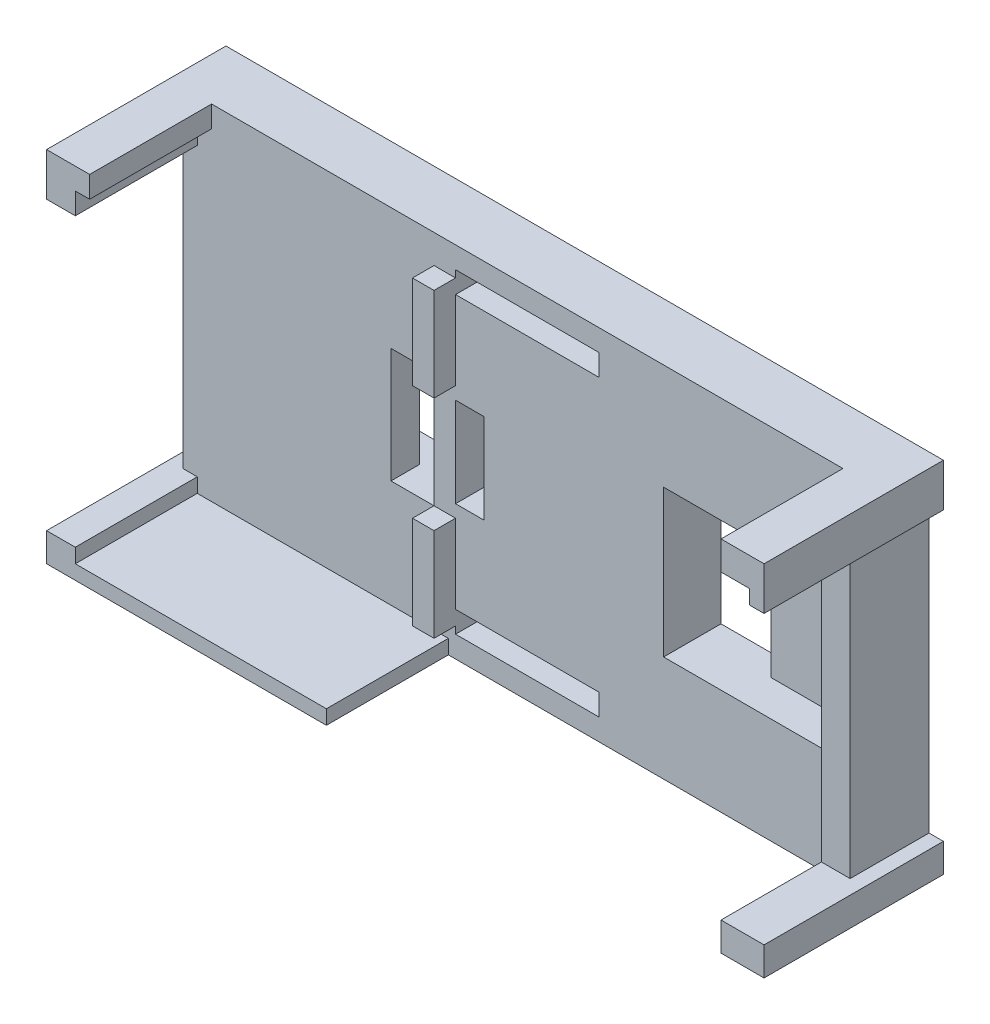
from build123d import *

# Parameters (mm, degrees)
SKIZZE1_W                            = 100
SKIZZE1_H                            = 50
SKIZZE1_W_2                          = 20
SKIZZE1_H_2                          = 3
AUFSATZ_LINEAR_AUSTRAGEN1_DEPTH      = 3
SKIZZE2_W                            = 90
SKIZZE2_H                            = 25
AUFSATZ_LINEAR_AUSTRAGEN2_DEPTH      = 5
SCHNITT_LINEAR_AUSTRAGEN1_DEPTH      = 4
SKIZZE4_W                            = 6
SKIZZE4_H                            = 16
SCHNITT_LINEAR_AUSTRAGEN2_DEPTH      = 5
SCHNITT_LINEAR_AUSTRAGEN2_DEPTH_BACK = 5
SKIZZE5_W                            = 25
SKIZZE5_H                            = 12.5
SCHNITT_LINEAR_AUSTRAGEN3_DEPTH      = 5.6
SKIZZE6_W                            = 4
SKIZZE6_H                            = 12.5
SCHNITT_LINEAR_AUSTRAGEN4_DEPTH      = 6.6
SCHNITT_LINEAR_AUSTRAGEN4_DEPTH_BACK = 3.4
SKIZZE8_W                            = 13
SKIZZE8_H                            = 20.5
SCHNITT_LINEAR_AUSTRAGEN5_DEPTH      = 5
SKIZZE9_W                            = 10
SKIZZE9_H                            = 20.5
SCHNITT_LINEAR_AUSTRAGEN6_DEPTH      = 8
AUFSATZ_LINEAR_AUSTRAGEN3_DEPTH      = 1
AUFSATZ_LINEAR_AUSTRAGEN4_DEPTH      = 17
SKIZZE14_W                           = 3
SKIZZE14_H                           = 42
AUFSATZ_LINEAR_AUSTRAGEN5_DEPTH      = 3
SKIZZE15_W                           = 3
SKIZZE15_H                           = 16
SCHNITT_LINEAR_AUSTRAGEN7_DEPTH      = 3
SKIZZE16_W                           = 2
SKIZZE16_H                           = 2
AUFSATZ_LINEAR_AUSTRAGEN6_DEPTH      = 17
SKIZZE17_W                           = 2
SKIZZE17_H                           = 40
SCHNITT_LINEAR_AUSTRAGEN8_DEPTH      = 20
SKIZZE18_W                           = 35
SKIZZE18_H                           = 2
SCHNITT_LINEAR_AUSTRAGEN9_DEPTH      = 17
SKIZZE19_W                           = 2
SKIZZE19_H                           = 6
SKIZZE19_W_2                         = 4
SKIZZE19_H_2                         = 4
AUFSATZ_LINEAR_AUSTRAGEN7_DEPTH      = 17
SKIZZE20_W                           = 1
SKIZZE20_H                           = 42
AUFSATZ_LINEAR_AUSTRAGEN8_DEPTH      = 3
SKIZZE21_W                           = 2
SKIZZE21_H                           = 3
AUFSATZ_LINEAR_AUSTRAGEN9_DEPTH      = 17
SKIZZE22_W                           = 20
SKIZZE22_H                           = 3
SKIZZE22_W_2                         = 90
SKIZZE22_H_2                         = 25
AUFSATZ_LINEAR_AUSTRAGEN10_DEPTH     = 5
SKIZZE24_W                           = 2
SKIZZE24_H                           = 4
AUFSATZ_LINEAR_AUSTRAGEN11_DEPTH     = 17


with BuildPart() as part:
    # Skizze1 → Aufsatz-Linear austragen1 (new body)
    with BuildSketch(Plane.XY):
        Rectangle(SKIZZE1_W, SKIZZE1_H)
        with Locations((0, -20.5)):
            Rectangle(SKIZZE1_W_2, SKIZZE1_H_2, mode=Mode.SUBTRACT)
        with Locations((0, 20.5)):
            Rectangle(SKIZZE1_W_2, SKIZZE1_H_2, mode=Mode.SUBTRACT)
    extrude(amount=AUFSATZ_LINEAR_AUSTRAGEN1_DEPTH)

    # Skizze2 → Aufsatz-Linear austragen2 (add)
    with BuildSketch(Plane(origin=(0, 0, 0), x_dir=(-1, 0, 0), z_dir=(0, 0, -1))):
        Rectangle(SKIZZE2_W, SKIZZE2_H)
    extrude(amount=AUFSATZ_LINEAR_AUSTRAGEN2_DEPTH)

    # Skizze3 → Schnitt-Linear austragen1 (cut)
    with BuildSketch(Plane(origin=(0, 0, -5), x_dir=(-1, 0, 0), z_dir=(0, 0, -1))):
        with BuildLine():
            Line((33, -8), (13, -8))
            Line((13, -8), (13, 8))
            Line((13, 8), (33, 8))
            ThreePointArc((33, 8), (41, 0), (33, -8))
        make_face()
    extrude(amount=-SCHNITT_LINEAR_AUSTRAGEN1_DEPTH, mode=Mode.SUBTRACT)

    # Skizze4 → Schnitt-Linear austragen2 (cut, two sides)
    with BuildSketch(Plane(origin=(0, 0, -1), x_dir=(-1, 0, 0), z_dir=(0, 0, -1))) as schnitt_linear_austragen2_sk:
        with Locations((16, 0)):
            Rectangle(SKIZZE4_W, SKIZZE4_H)
    extrude(amount=SCHNITT_LINEAR_AUSTRAGEN2_DEPTH, mode=Mode.SUBTRACT)
    extrude(schnitt_linear_austragen2_sk.sketch, amount=-SCHNITT_LINEAR_AUSTRAGEN2_DEPTH_BACK, mode=Mode.SUBTRACT)

    # Skizze5 → Schnitt-Linear austragen3 (cut)
    with BuildSketch(Plane(origin=(0, 0, -5), x_dir=(-1, 0, 0), z_dir=(0, 0, -1))):
        with Locations((-2.5, 0)):
            Rectangle(SKIZZE5_W, SKIZZE5_H)
    extrude(amount=-SCHNITT_LINEAR_AUSTRAGEN3_DEPTH, mode=Mode.SUBTRACT)

    # Skizze6 → Schnitt-Linear austragen4 (cut, two sides)
    with BuildSketch(Plane(origin=(0, 0, 0.6), x_dir=(-1, 0, 0), z_dir=(0, 0, -1))) as schnitt_linear_austragen4_sk:
        with Locations((8, 0)):
            Rectangle(SKIZZE6_W, SKIZZE6_H)
    extrude(amount=SCHNITT_LINEAR_AUSTRAGEN4_DEPTH, mode=Mode.SUBTRACT)
    extrude(schnitt_linear_austragen4_sk.sketch, amount=-SCHNITT_LINEAR_AUSTRAGEN4_DEPTH_BACK, mode=Mode.SUBTRACT)

    # Skizze8 → Schnitt-Linear austragen5 (cut)
    with BuildSketch(Plane.XY.offset(3)):
        with Locations((35.5, 0)):
            Rectangle(SKIZZE8_W, SKIZZE8_H)
    extrude(amount=-SCHNITT_LINEAR_AUSTRAGEN5_DEPTH, mode=Mode.SUBTRACT)

    # Skizze9 → Schnitt-Linear austragen6 (cut)
    with BuildSketch(Plane.XY.offset(3)):
        with Locations((24, 0)):
            Rectangle(SKIZZE9_W, SKIZZE9_H)
    extrude(amount=-SCHNITT_LINEAR_AUSTRAGEN6_DEPTH, mode=Mode.SUBTRACT)

    # Skizze10 → Aufsatz-Linear austragen3 (add)
    with BuildSketch(Plane(origin=(0, 0, -5), x_dir=(-1, 0, 0), z_dir=(0, 0, -1))):
        with BuildLine():
            Line((38.291502622, -6), (38.291502622, 6))
            ThreePointArc((38.291502622, 6), (41, 0), (38.291502622, -6))
        make_face()
    extrude(amount=-AUFSATZ_LINEAR_AUSTRAGEN3_DEPTH)

    # Skizze11 → Aufsatz-Linear austragen4 (add)
    with BuildSketch(Plane.XY.offset(3)):
        Polygon((-50, 25), (-50, -25), (-48, -25), (-11, -25), (-11, -23), (-48, -23), (-48, 25), align=None)
        Polygon((50, -25), (50, 25), (48, 25), (48, -23), (11, -23), (11, -25), align=None)
    extrude(amount=AUFSATZ_LINEAR_AUSTRAGEN4_DEPTH)

    # Skizze14 → Aufsatz-Linear austragen5 (add)
    with BuildSketch(Plane.XY.offset(3)):
        with Locations((-11.5, 0)):
            Rectangle(SKIZZE14_W, SKIZZE14_H)
        with Locations((45.5, 0)):
            Rectangle(SKIZZE14_W, SKIZZE14_H)
    extrude(amount=AUFSATZ_LINEAR_AUSTRAGEN5_DEPTH)

    # Skizze15 → Schnitt-Linear austragen7 (cut)
    with BuildSketch(Plane.XY.offset(6)):
        with Locations((-11.5, 0)):
            Rectangle(SKIZZE15_W, SKIZZE15_H)
    extrude(amount=-SCHNITT_LINEAR_AUSTRAGEN7_DEPTH, mode=Mode.SUBTRACT)

    # Skizze16 → Aufsatz-Linear austragen6 (add)
    with BuildSketch(Plane.XY.offset(3)):
        with Locations((-47, -22)):
            Rectangle(SKIZZE16_W, SKIZZE16_H)
        with Locations((47, -22)):
            Rectangle(SKIZZE16_W, SKIZZE16_H)
    extrude(amount=AUFSATZ_LINEAR_AUSTRAGEN6_DEPTH)

    # Skizze17 → Schnitt-Linear austragen8 (cut)
    with BuildSketch(Plane.XY.offset(20)):
        with Locations((-49, -1)):
            Rectangle(SKIZZE17_W, SKIZZE17_H)
        with Locations((49, -1)):
            Rectangle(SKIZZE17_W, SKIZZE17_H)
    extrude(amount=-SCHNITT_LINEAR_AUSTRAGEN8_DEPTH, mode=Mode.SUBTRACT)

    # Skizze18 → Schnitt-Linear austragen9 (cut)
    with BuildSketch(Plane.XY.offset(20)):
        with Locations((28.5, -24)):
            Rectangle(SKIZZE18_W, SKIZZE18_H)
    extrude(amount=-SCHNITT_LINEAR_AUSTRAGEN9_DEPTH, mode=Mode.SUBTRACT)

    # Skizze19 → Aufsatz-Linear austragen7 (add)
    with BuildSketch(Plane.XY.offset(3)):
        with Locations((-47, 22)):
            Rectangle(SKIZZE19_W, SKIZZE19_H)
        with Locations((46, 23)):
            Rectangle(SKIZZE19_W_2, SKIZZE19_H_2)
    extrude(amount=AUFSATZ_LINEAR_AUSTRAGEN7_DEPTH)

    # Skizze20 → Aufsatz-Linear austragen8 (add)
    with BuildSketch(Plane.XY.offset(3)):
        with Locations((47.5, 0)):
            Rectangle(SKIZZE20_W, SKIZZE20_H)
    extrude(amount=AUFSATZ_LINEAR_AUSTRAGEN8_DEPTH)

    # Skizze21 → Aufsatz-Linear austragen9 (add)
    with BuildSketch(Plane.XY.offset(3)):
        with Locations((-45, 23.5)):
            Rectangle(SKIZZE21_W, SKIZZE21_H)
    extrude(amount=AUFSATZ_LINEAR_AUSTRAGEN9_DEPTH)

    # Skizze22 → Aufsatz-Linear austragen10 (add)
    with BuildSketch(Plane(origin=(0, 0, 0), x_dir=(-1, 0, 0), z_dir=(0, 0, -1))):
        Polygon((-50, 19), (-50, 25), (50, 25), (50, 19), (48, 19), (48, -21), (50, -21), (50, -25), (-50, -25), (-50, -21), (-48, -21), (-48, 19), align=None)
        with Locations((0, 20.5)):
            Rectangle(SKIZZE22_W, SKIZZE22_H, mode=Mode.SUBTRACT)
        Rectangle(SKIZZE22_W_2, SKIZZE22_H_2, mode=Mode.SUBTRACT)
        with Locations((0, -20.5)):
            Rectangle(SKIZZE22_W, SKIZZE22_H, mode=Mode.SUBTRACT)
    extrude(amount=AUFSATZ_LINEAR_AUSTRAGEN10_DEPTH)

    # Skizze24 → Aufsatz-Linear austragen11 (add)
    with BuildSketch(Plane.XY.offset(3)):
        with Locations((45, -23)):
            Rectangle(SKIZZE24_W, SKIZZE24_H)
    extrude(amount=AUFSATZ_LINEAR_AUSTRAGEN11_DEPTH)


solid = part.part
